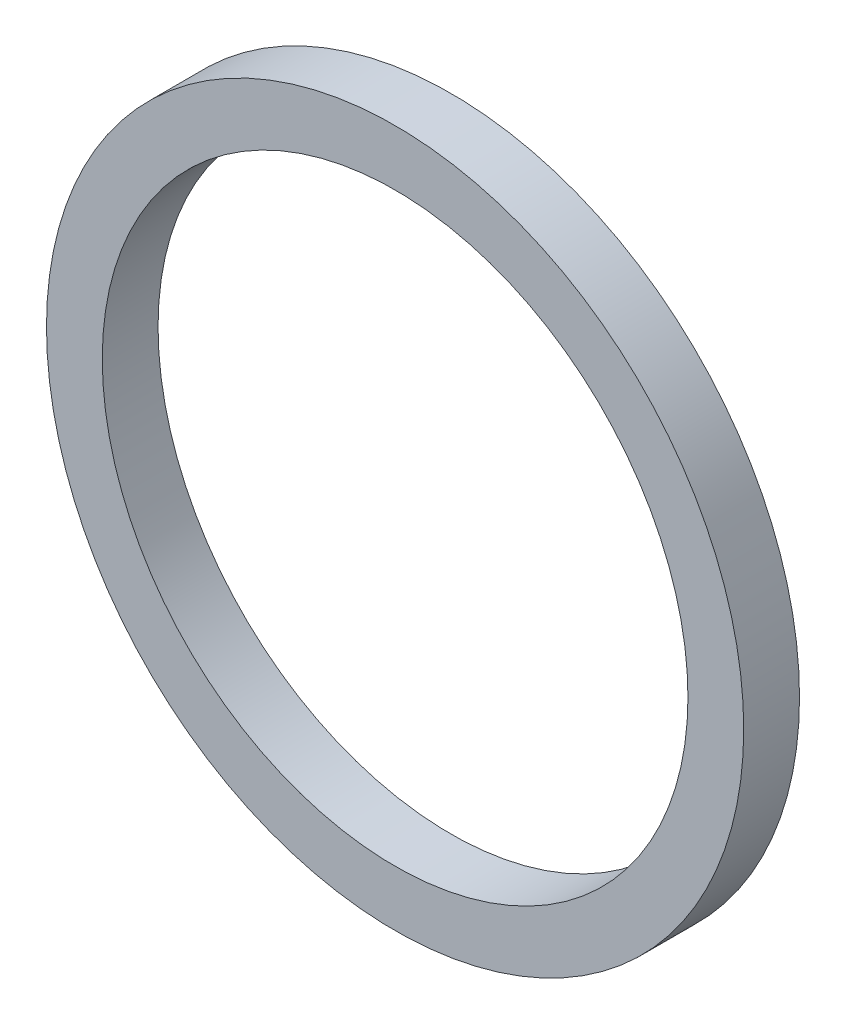
from build123d import *

# Parameters (mm, degrees)
SKETCH1_R           = 18.75
SKETCH1_R_2         = 15.75
BOSS_EXTRUDE1_DEPTH = 3


with BuildPart() as part:
    # Sketch1 → Boss-Extrude1 (new body)
    with BuildSketch(Plane.XY):
        Circle(SKETCH1_R)
        Circle(SKETCH1_R_2, mode=Mode.SUBTRACT)
    extrude(amount=BOSS_EXTRUDE1_DEPTH)


solid = part.part
